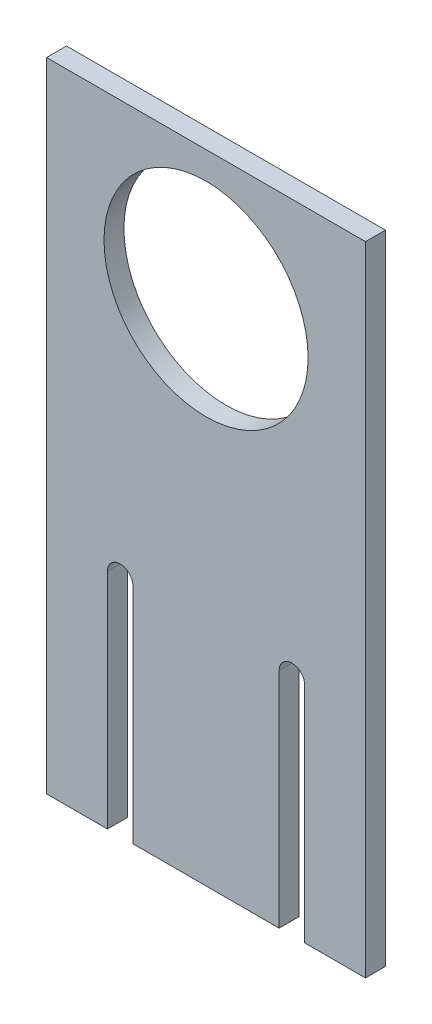
from build123d import *

# Parameters (mm, degrees)
ESBO_O1_W                = 50
ESBO_O1_H                = 100
RESSALTO_EXTRUS_O1_DEPTH = 3.125
ESBO_O2_R                = 16
CORTE_EXTRUS_O1_DEPTH    = 3.125


with BuildPart() as part:
    # Esboço1 → Ressalto-extrusão1 (new body)
    with BuildSketch(Plane.XY):
        with Locations((-25, 50)):
            Rectangle(ESBO_O1_W, ESBO_O1_H)
    extrude(amount=RESSALTO_EXTRUS_O1_DEPTH)

    # Esboço2 → Corte-extrusão1 (cut)
    with BuildSketch(Plane.XY.offset(3.125)):
        with Locations((-25, 79.712786513)):
            Circle(ESBO_O2_R)
        with BuildLine():
            Line((-36.464726097, 35), (-36.464726097, 0))
            Line((-36.464726097, 0), (-40.464726097, 0))
            Line((-40.464726097, 0), (-40.464726097, 35))
            ThreePointArc((-40.464726097, 35), (-38.464726097, 37), (-36.464726097, 35))
        make_face()
        with BuildLine():
            Line((-13.535273903, 35), (-13.535273903, 0))
            Line((-13.535273903, 0), (-9.535273903, 0))
            Line((-9.535273903, 0), (-9.535273903, 35))
            ThreePointArc((-9.535273903, 35), (-11.535273903, 37), (-13.535273903, 35))
        make_face()
    extrude(amount=-CORTE_EXTRUS_O1_DEPTH, mode=Mode.SUBTRACT)


solid = part.part
